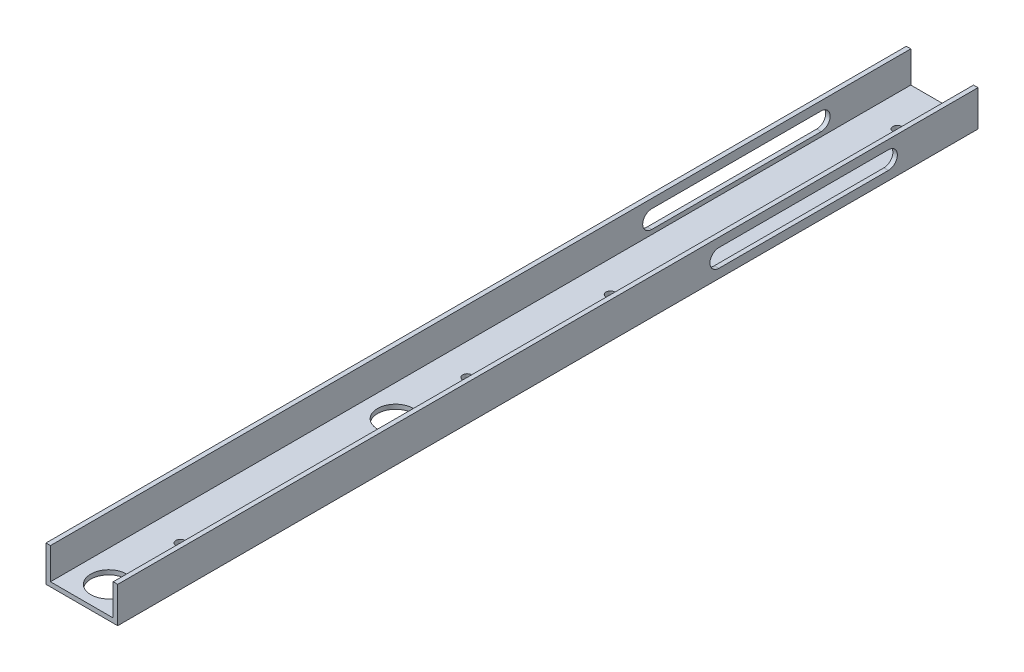
from build123d import *

# Parameters (mm, degrees)
BOSS_EXTRUDE1_DEPTH = 609.6
CUT_EXTRUDE1_REACH  = 5.175
SKETCH2_R           = 12.7
SKETCH2_R_2         = 3.175
CUT_EXTRUDE2_REACH  = 5.175
SKETCH3_R           = 3.175
CUT_EXTRUDE3_DEPTH  = 51.8


with BuildPart() as part:
    # Sketch1 → Boss-Extrude1 (new body)
    with BuildSketch(Plane.XY):
        Polygon((47.625, 3.175), (47.625, 25.4), (50.8, 25.4), (50.8, 0), (0, 0), (0, 25.4), (3.175, 25.4), (3.175, 3.175), align=None)
    extrude(amount=BOSS_EXTRUDE1_DEPTH)

    # Sketch2 → Cut-Extrude1 (cut, up to next)
    with BuildSketch(Plane(origin=(0, 3.175, 0), x_dir=(1, 0, 0), z_dir=(0, 1, 0)), mode=Mode.PRIVATE) as cut_extrude1_sk1:
        with Locations((25.4, -590.55)):
            Circle(SKETCH2_R)
    cut_extrude1_tool1 = extrude(cut_extrude1_sk1.sketch, amount=-CUT_EXTRUDE1_REACH, mode=Mode.PRIVATE) & part.part
    add(cut_extrude1_tool1.solids().sort_by_distance((25.4, 3.175, 590.55))[0], mode=Mode.SUBTRACT)
    # Sketch2 → Cut-Extrude1 (cut, up to next)
    with BuildSketch(Plane(origin=(0, 3.175, 0), x_dir=(1, 0, 0), z_dir=(0, 1, 0)), mode=Mode.PRIVATE) as cut_extrude1_sk2:
        with Locations((25.4, -387.35)):
            Circle(SKETCH2_R)
    cut_extrude1_tool2 = extrude(cut_extrude1_sk2.sketch, amount=-CUT_EXTRUDE1_REACH, mode=Mode.PRIVATE) & part.part
    add(cut_extrude1_tool2.solids().sort_by_distance((25.4, 3.175, 387.35))[0], mode=Mode.SUBTRACT)
    # Sketch2 → Cut-Extrude1 (cut, up to next)
    with BuildSketch(Plane(origin=(0, 3.175, 0), x_dir=(1, 0, 0), z_dir=(0, 1, 0)), mode=Mode.PRIVATE) as cut_extrude1_sk3:
        with Locations((25.4, -539.75)):
            Circle(SKETCH2_R_2)
    cut_extrude1_tool3 = extrude(cut_extrude1_sk3.sketch, amount=-CUT_EXTRUDE1_REACH, mode=Mode.PRIVATE) & part.part
    add(cut_extrude1_tool3.solids().sort_by_distance((25.4, 3.175, 539.75))[0], mode=Mode.SUBTRACT)
    # Sketch2 → Cut-Extrude1 (cut, up to next)
    with BuildSketch(Plane(origin=(0, 3.175, 0), x_dir=(1, 0, 0), z_dir=(0, 1, 0)), mode=Mode.PRIVATE) as cut_extrude1_sk4:
        with Locations((25.4, -336.55)):
            Circle(SKETCH2_R_2)
    cut_extrude1_tool4 = extrude(cut_extrude1_sk4.sketch, amount=-CUT_EXTRUDE1_REACH, mode=Mode.PRIVATE) & part.part
    add(cut_extrude1_tool4.solids().sort_by_distance((25.4, 3.175, 336.55))[0], mode=Mode.SUBTRACT)

    # Sketch3 → Cut-Extrude2 (cut, up to next)
    with BuildSketch(Plane(origin=(0, 3.175, 0), x_dir=(1, 0, 0), z_dir=(0, 1, 0)), mode=Mode.PRIVATE) as cut_extrude2_sk1:
        with Locations((25.4, -234.95)):
            Circle(SKETCH3_R)
    cut_extrude2_tool1 = extrude(cut_extrude2_sk1.sketch, amount=-CUT_EXTRUDE2_REACH, mode=Mode.PRIVATE) & part.part
    add(cut_extrude2_tool1.solids().sort_by_distance((25.4, 3.175, 234.95))[0], mode=Mode.SUBTRACT)
    # Sketch3 → Cut-Extrude2 (cut, up to next)
    with BuildSketch(Plane(origin=(0, 3.175, 0), x_dir=(1, 0, 0), z_dir=(0, 1, 0)), mode=Mode.PRIVATE) as cut_extrude2_sk2:
        with Locations((25.4, -31.75)):
            Circle(SKETCH3_R)
    cut_extrude2_tool2 = extrude(cut_extrude2_sk2.sketch, amount=-CUT_EXTRUDE2_REACH, mode=Mode.PRIVATE) & part.part
    add(cut_extrude2_tool2.solids().sort_by_distance((25.4, 3.175, 31.75))[0], mode=Mode.SUBTRACT)

    # Sketch4 → Cut-Extrude3 (cut, through all)
    with BuildSketch(Plane(origin=(50.8, 0, 0), x_dir=(0, 0, -1), z_dir=(1, 0, 0))):
        with BuildLine():
            Line((-183.606708986, 19.05), (-63.5, 19.05))
            ThreePointArc((-63.5, 19.05), (-57.15, 12.7), (-63.5, 6.35))
            Line((-63.5, 6.35), (-183.606708986, 6.35))
            ThreePointArc((-183.606708986, 6.35), (-189.956708986, 12.7), (-183.606708986, 19.05))
        make_face()
    extrude(amount=-CUT_EXTRUDE3_DEPTH, mode=Mode.SUBTRACT)


solid = part.part
